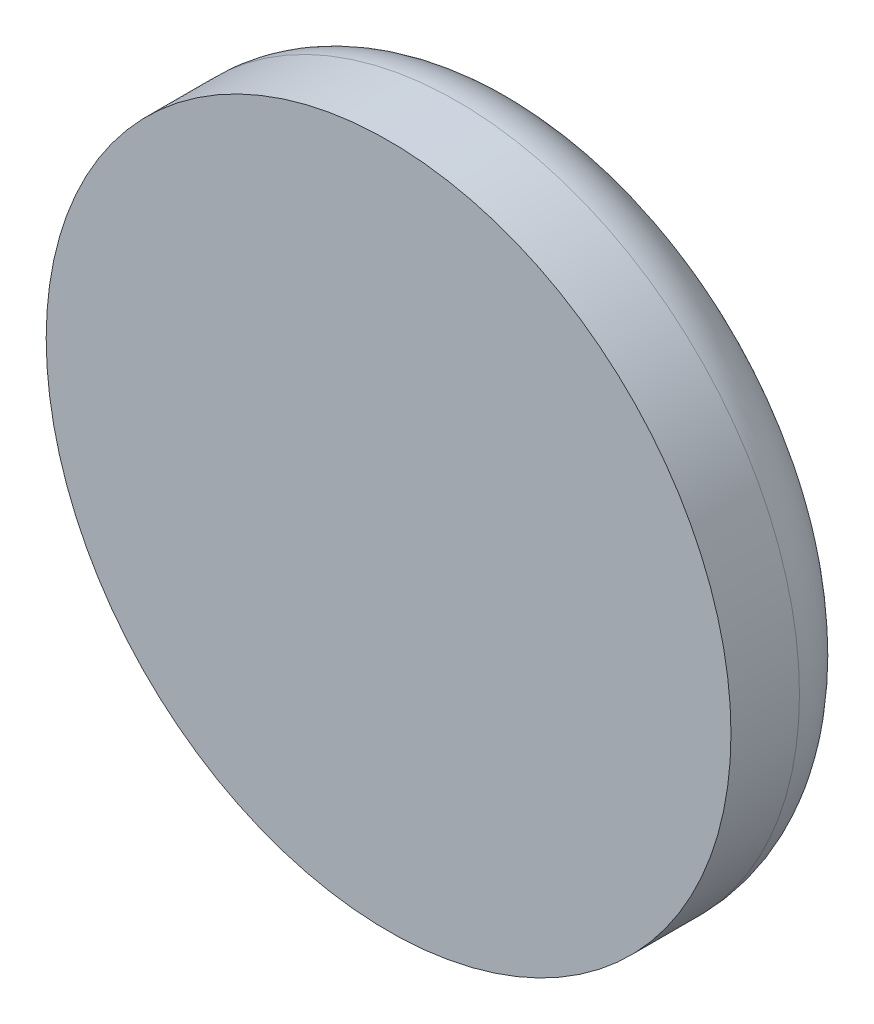
from build123d import *


with BuildPart() as part:
    # Sketch1 → Revolve1 (revolve)
    with BuildSketch(Plane(origin=(0, 15.152992085, 0), x_dir=(1, 0, 0), z_dir=(0, 1, 0))):
        with BuildLine():
            Line((1, 4.946698122), (0, 4.946698122))
            Line((0, 4.946698122), (0, 4.346698122))
            Line((0, 4.346698122), (5, 4.346698122))
            Line((5, 4.346698122), (5, 5.346698122))
            ThreePointArc((5, 5.346698122), (4.707106781, 6.053804904), (4, 6.346698122))
            Line((4, 6.346698122), (1, 6.346698122))
            Line((1, 6.346698122), (1, 4.946698122))
        make_face()
    revolve(axis=Axis((0, 15.152992085, -6.346698122), (0, 0, 1)))


solid = part.part
